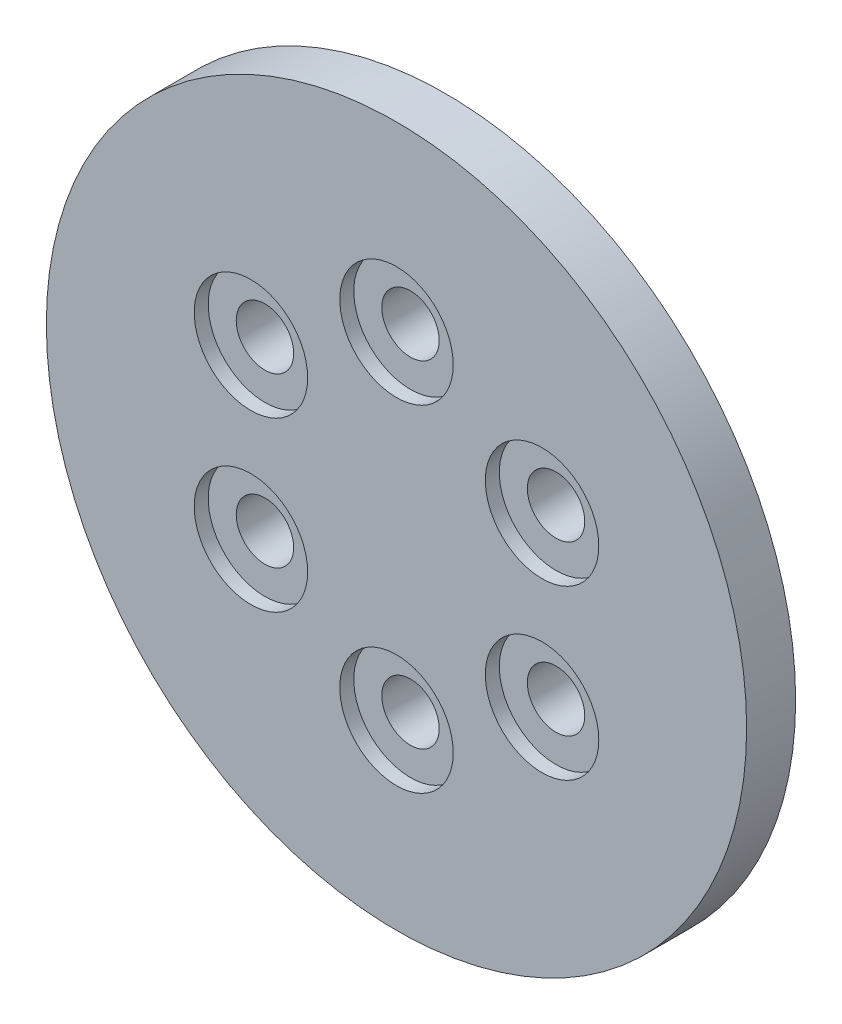
from build123d import *

# Parameters (mm, degrees)
SKETCH_1_R          = 25
EXTRUDE_1_DEPTH     = 4
SKETCH_4_R          = 2.05
CUT_EXTRUDE_1_DEPTH = 10
SKETCH_5_R          = 4.05
SKETCH_5_R_2        = 2.05
CUT_EXTRUDE_2_DEPTH = 1
SKETCH_6_R          = 25
SKETCH_6_R_2        = 20
CUT_EXTRUDE_3_DEPTH = 0.5


with BuildPart() as part:
    # 草图1 → 凸台-拉伸1 (new body)
    with BuildSketch(Plane.XY):
        Circle(SKETCH_1_R)
    extrude(amount=EXTRUDE_1_DEPTH)

    # 草图4 → 切除-拉伸1 (cut)
    with BuildSketch(Plane(origin=(0, 0, 0), x_dir=(-1, 0, 0), z_dir=(0, 0, -1))):
        with Locations((-10.392304845, -6)):
            Circle(SKETCH_4_R)
        with Locations((-10.392304845, 6)):
            Circle(SKETCH_4_R)
        with Locations((0, 12)):
            Circle(SKETCH_4_R)
        with Locations((10.392304845, 6)):
            Circle(SKETCH_4_R)
        with Locations((10.392304845, -6)):
            Circle(SKETCH_4_R)
        with Locations((0, -12)):
            Circle(SKETCH_4_R)
    extrude(amount=-CUT_EXTRUDE_1_DEPTH, mode=Mode.SUBTRACT)

    # 草图5 → 切除-拉伸2 (cut)
    with BuildSketch(Plane.XY.offset(4)):
        with Locations((-10.392304845, 6)):
            Circle(SKETCH_5_R)
        with Locations((-10.392304845, 6)):
            Circle(SKETCH_5_R_2, mode=Mode.SUBTRACT)
        with Locations((-10.392304845, -6)):
            Circle(SKETCH_5_R)
        with Locations((-10.392304845, -6)):
            Circle(SKETCH_5_R_2, mode=Mode.SUBTRACT)
        with Locations((0, -12)):
            Circle(SKETCH_5_R)
        with Locations((0, -12)):
            Circle(SKETCH_5_R_2, mode=Mode.SUBTRACT)
        with Locations((10.392304845, -6)):
            Circle(SKETCH_5_R)
        with Locations((10.392304845, -6)):
            Circle(SKETCH_5_R_2, mode=Mode.SUBTRACT)
        with Locations((10.392304845, 6)):
            Circle(SKETCH_5_R)
        with Locations((10.392304845, 6)):
            Circle(SKETCH_5_R_2, mode=Mode.SUBTRACT)
        with Locations((0, 12)):
            Circle(SKETCH_5_R)
        with Locations((0, 12)):
            Circle(SKETCH_5_R_2, mode=Mode.SUBTRACT)
    extrude(amount=-CUT_EXTRUDE_2_DEPTH, mode=Mode.SUBTRACT)

    # 草图6 → 切除-拉伸3 (cut)
    with BuildSketch(Plane(origin=(0, 0, 0), x_dir=(-1, 0, 0), z_dir=(0, 0, -1))):
        Circle(SKETCH_6_R)
        Circle(SKETCH_6_R_2, mode=Mode.SUBTRACT)
    extrude(amount=-CUT_EXTRUDE_3_DEPTH, mode=Mode.SUBTRACT)


solid = part.part
